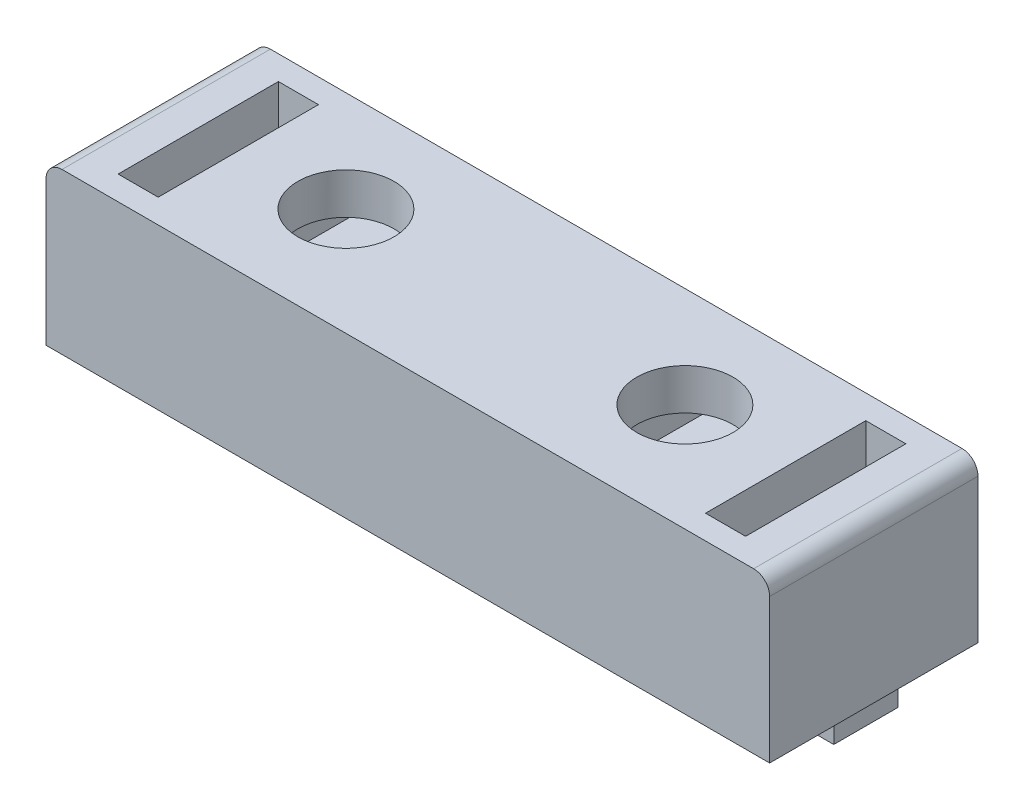
from build123d import *

# Parameters (mm, degrees)
SKETCH1_W           = 90.3
SKETCH1_H           = 26
BOSS_EXTRUDE1_DEPTH = 20
SKETCH2_W           = 5
SKETCH2_H           = 20
CUT_EXTRUDE1_DEPTH  = 21
LPATTERN1_COUNT     = 2
LPATTERN1_PITCH     = 73.3
SKETCH3_R           = 6
CUT_EXTRUDE2_DEPTH  = 18
SKETCH4_W           = 19
SKETCH4_H           = 6
CUT_EXTRUDE3_DEPTH  = 22.5
SKETCH5_W           = 3
SKETCH5_H           = 8
BOSS_EXTRUDE2_DEPTH = 3
FILLET1_R           = 2


with BuildPart() as part:
    # Sketch1 → Boss-Extrude1 (new body)
    with BuildSketch(Plane(origin=(0, 0, 0), x_dir=(1, 0, 0), z_dir=(0, 1, 0))):
        with Locations((17.15729927, -0.427007299)):
            Rectangle(SKETCH1_W, SKETCH1_H)
    extrude(amount=-BOSS_EXTRUDE1_DEPTH)

    # Sketch2 → Cut-Extrude1 (cut, through all)
    with BuildSketch(Plane(origin=(0, 0, 0), x_dir=(1, 0, 0), z_dir=(0, 1, 0))):
        with Locations((53.80729927, -0.427007299)):
            Rectangle(SKETCH2_W, SKETCH2_H)
    cut_extrude1 = extrude(amount=-CUT_EXTRUDE1_DEPTH, mode=Mode.SUBTRACT)

    # LPattern1: Cut-Extrude1 ×2
    with Locations(*[(-i * LPATTERN1_PITCH, 0, 0) for i in range(1, LPATTERN1_COUNT)]):
        add(cut_extrude1, mode=Mode.SUBTRACT)

    # Sketch3 → Cut-Extrude2 (cut)
    with BuildSketch(Plane(origin=(0, 0, 0), x_dir=(1, 0, 0), z_dir=(0, 1, 0))):
        with Locations((38.30729927, 0)):
            Circle(SKETCH3_R)
        with Locations((-3.99270073, 0)):
            Circle(SKETCH3_R)
    extrude(amount=-CUT_EXTRUDE2_DEPTH, mode=Mode.SUBTRACT)

    # Sketch4 → Cut-Extrude3 (cut)
    with BuildSketch(Plane(origin=(0, 0, -12.572992701), x_dir=(-1, 0, 0), z_dir=(0, 0, -1))):
        with Locations((-38.80729927, -8.129091999)):
            Rectangle(SKETCH4_W, SKETCH4_H)
        with Locations((4.49270073, -8.129091999)):
            Rectangle(SKETCH4_W, SKETCH4_H)
    extrude(amount=-CUT_EXTRUDE3_DEPTH, mode=Mode.SUBTRACT)

    # Sketch5 → Boss-Extrude2 (add)
    with BuildSketch(Plane.XZ.offset(20)):
        with Locations((59.80729927, 0.427007299)):
            Rectangle(SKETCH5_W, SKETCH5_H)
        with Locations((-24.99270073, 0.427007299)):
            Rectangle(SKETCH5_W, SKETCH5_H)
    extrude(amount=BOSS_EXTRUDE2_DEPTH)

    # Fillet1
    fillet1_edges = [part.edges().sort_by_distance(p)[0] for p in [
        (62.30729927, 0, 0.427007299),
        (-27.99270073, 0, 0.427007299),
    ]]
    fillet(fillet1_edges, radius=FILLET1_R)


solid = part.part
